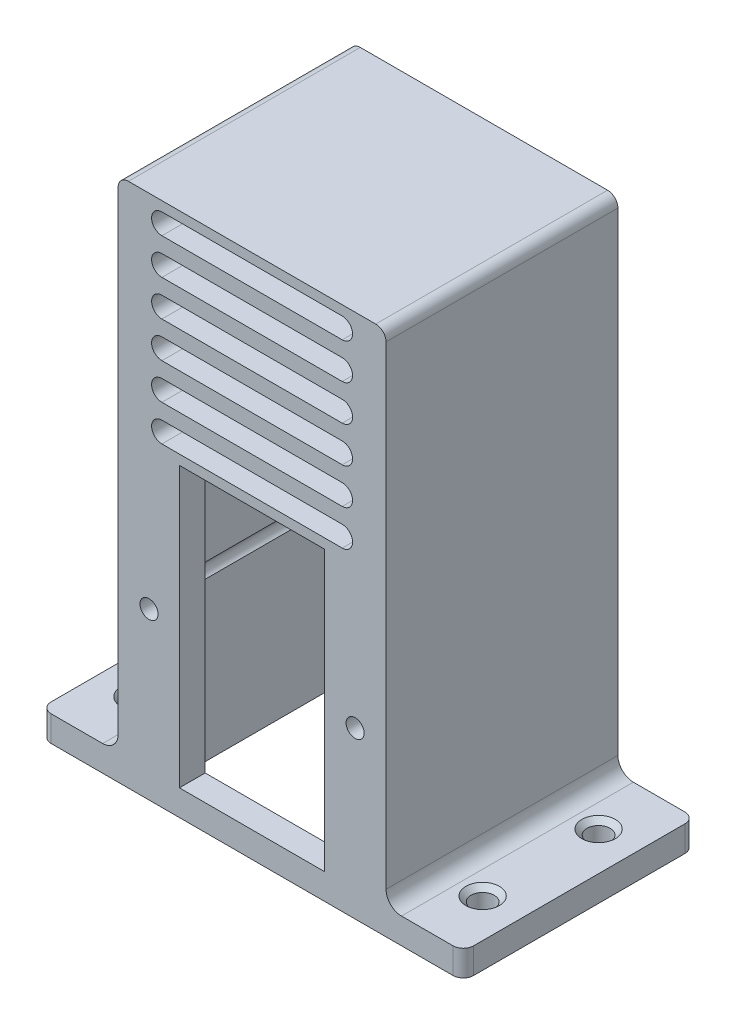
from build123d import *

# Parameters (mm, degrees)
RESSALTO_EXTRUS_O4_DEPTH = 5
RESSALTO_EXTRUS_O6_DEPTH = 102
ESBO_O9_W                = 52
ESBO_O9_H                = 5
RESSALTO_EXTRUS_O7_DEPTH = 45
ESBO_O10_R               = 2.25
CORTE_EXTRUS_O1_DEPTH    = 103
FILETE1_R                = 3
FILETE3_R                = 2
FILETE5_R                = 2
ESBO_O11_R               = 1.75
ESBO_O11_W               = 28.2
ESBO_O11_H               = 54.2
CORTE_EXTRUS_O2_DEPTH    = 46
CORTE_EXTRUS_O3_DEPTH    = 46
CHANFRO1_SIZE            = 1


with BuildPart() as part:
    # Esboço7 → Ressalto-extrusão4 (new body)
    with BuildSketch(Plane(origin=(0, 0, 0), x_dir=(1, 0, 0), z_dir=(0, 1, 0))):
        Polygon((21, 45), (21, 5), (-21, 5), (-21, 45), (-41, 45), (-41, 0), (41, 0), (41, 45), align=None)
    extrude(amount=RESSALTO_EXTRUS_O4_DEPTH)

    # Esboço8 → Ressalto-extrusão6 (add)
    with BuildSketch(Plane(origin=(0, 0, 0), x_dir=(1, 0, 0), z_dir=(0, 1, 0))):
        Polygon((-21, 45), (-26, 45), (-26, 0), (26, 0), (26, 45), (21, 45), (21, 5), (-21, 5), align=None)
    extrude(amount=RESSALTO_EXTRUS_O6_DEPTH)

    # Esboço9 → Ressalto-extrusão7 (add)
    with BuildSketch(Plane.XY):
        with Locations((0, 99.5)):
            Rectangle(ESBO_O9_W, ESBO_O9_H)
    extrude(amount=-RESSALTO_EXTRUS_O7_DEPTH)

    # Esboço10 → Corte-extrusão1 (cut, through all)
    with BuildSketch(Plane(origin=(0, 0, 0), x_dir=(1, 0, 0), z_dir=(0, 1, 0))):
        with Locations((-33.5, 33.75)):
            Circle(ESBO_O10_R)
        with Locations((-33.5, 11.25)):
            Circle(ESBO_O10_R)
        with Locations((33.5, 11.25)):
            Circle(ESBO_O10_R)
        with Locations((33.5, 33.75)):
            Circle(ESBO_O10_R)
    extrude(amount=CORTE_EXTRUS_O1_DEPTH, mode=Mode.SUBTRACT)

    # Filete1
    filete1_edges = [part.edges().sort_by_distance(p)[0] for p in [
        (-26, 5, -22.5),
        (26, 5, -22.5),
    ]]
    fillet(filete1_edges, radius=FILETE1_R)

    # Filete3
    filete3_edges = [part.edges().sort_by_distance(p)[0] for p in [
        (41, 2.5, 0),
        (-41, 2.5, 0),
        (-41, 2.5, -45),
        (41, 2.5, -45),
    ]]
    fillet(filete3_edges, radius=FILETE3_R)

    # Filete5
    filete5_edges = [part.edges().sort_by_distance(p)[0] for p in [
        (-26, 102, -22.5),
        (26, 102, -22.5),
    ]]
    fillet(filete5_edges, radius=FILETE5_R)

    # Esboço11 → Corte-extrusão2 (cut, through all)
    with BuildSketch(Plane.XY):
        with Locations((20, 32.1)):
            Circle(ESBO_O11_R)
        with Locations((-20, 32.1)):
            Circle(ESBO_O11_R)
        with Locations((0, 32.1)):
            Rectangle(ESBO_O11_W, ESBO_O11_H)
    extrude(amount=-CORTE_EXTRUS_O2_DEPTH, mode=Mode.SUBTRACT)

    # Esboço12 → Corte-extrusão3 (cut, through all)
    with BuildSketch(Plane.XY):
        with BuildLine():
            Line((-17.5, 100.1), (17.5, 100.1))
            ThreePointArc((17.5, 100.1), (19.5, 98.1), (17.5, 96.1))
            Line((17.5, 96.1), (-17.5, 96.1))
            ThreePointArc((-17.5, 96.1), (-19.5, 98.1), (-17.5, 100.1))
        make_face()
        with BuildLine():
            Line((-17.5, 93.1), (17.5, 93.1))
            ThreePointArc((17.5, 93.1), (19.5, 91.1), (17.5, 89.1))
            Line((17.5, 89.1), (-17.5, 89.1))
            ThreePointArc((-17.5, 89.1), (-19.5, 91.1), (-17.5, 93.1))
        make_face()
        with BuildLine():
            Line((-17.5, 86.1), (17.5, 86.1))
            ThreePointArc((17.5, 86.1), (19.5, 84.1), (17.5, 82.1))
            Line((17.5, 82.1), (-17.5, 82.1))
            ThreePointArc((-17.5, 82.1), (-19.5, 84.1), (-17.5, 86.1))
        make_face()
        with BuildLine():
            Line((-17.5, 79.1), (17.5, 79.1))
            ThreePointArc((17.5, 79.1), (19.5, 77.1), (17.5, 75.1))
            Line((17.5, 75.1), (-17.5, 75.1))
            ThreePointArc((-17.5, 75.1), (-19.5, 77.1), (-17.5, 79.1))
        make_face()
        with BuildLine():
            Line((-17.5, 72.1), (17.5, 72.1))
            ThreePointArc((17.5, 72.1), (19.5, 70.1), (17.5, 68.1))
            Line((17.5, 68.1), (-17.5, 68.1))
            ThreePointArc((-17.5, 68.1), (-19.5, 70.1), (-17.5, 72.1))
        make_face()
        with BuildLine():
            Line((-17.5, 65.1), (17.5, 65.1))
            ThreePointArc((17.5, 65.1), (19.5, 63.1), (17.5, 61.1))
            Line((17.5, 61.1), (-17.5, 61.1))
            ThreePointArc((-17.5, 61.1), (-19.5, 63.1), (-17.5, 65.1))
        make_face()
    extrude(amount=-CORTE_EXTRUS_O3_DEPTH, mode=Mode.SUBTRACT)

    # Chanfro1
    chanfro1_edges = [part.edges().sort_by_distance(p)[0] for p in [
        (31.25, 5, -33.75),
        (31.25, 5, -11.25),
        (-35.75, 5, -11.25),
        (-35.75, 5, -33.75),
    ]]
    chamfer(chanfro1_edges, length=CHANFRO1_SIZE)


solid = part.part
